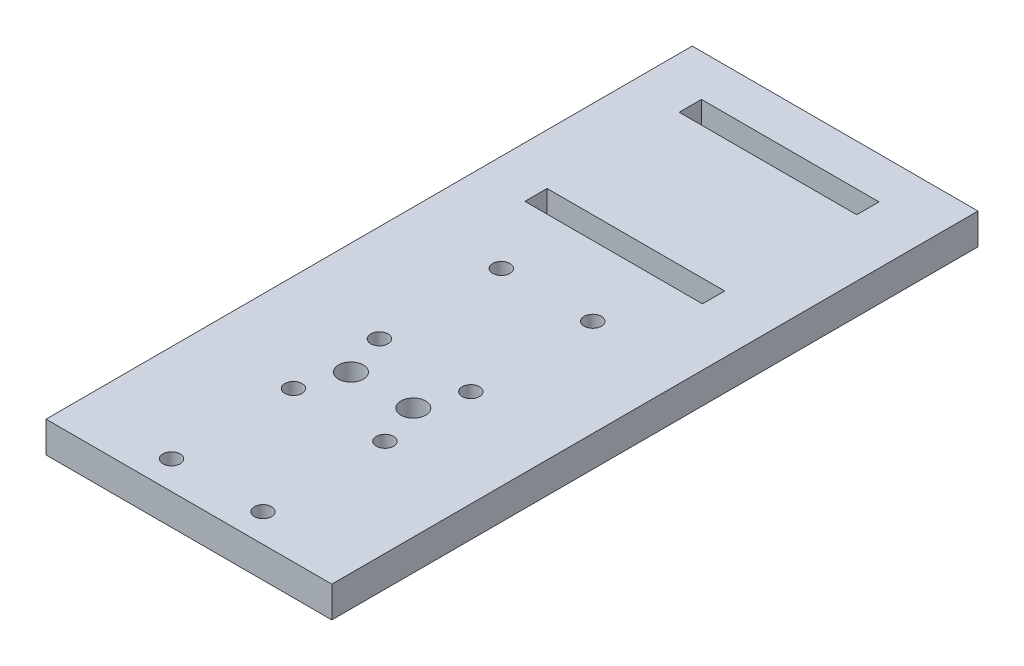
from build123d import *

# Parameters (mm, degrees)
SKETCH1_W           = 55
SKETCH1_H           = 74.38
SKETCH1_R           = 1.66
SKETCH1_R_2         = 2.38125
BOSS_EXTRUDE1_DEPTH = 5.969
SKETCH2_W           = 55
SKETCH2_H           = 49.98
SKETCH2_W_2         = 34.17
SKETCH2_H_2         = 4.28
BOSS_EXTRUDE2_DEPTH = 5.969


with BuildPart() as part:
    # Sketch1 → Boss-Extrude1 (new body)
    with BuildSketch(Plane(origin=(0, 0, 0), x_dir=(1, 0, 0), z_dir=(0, 1, 0))):
        with Locations((27.5, 37.19)):
            Rectangle(SKETCH1_W, SKETCH1_H)
        with Locations((18.7, 68.92)):
            Circle(SKETCH1_R, mode=Mode.SUBTRACT)
        with Locations((36.3, 68.92)):
            Circle(SKETCH1_R, mode=Mode.SUBTRACT)
        with Locations((36.3, 45.46)):
            Circle(SKETCH1_R, mode=Mode.SUBTRACT)
        with Locations((18.7, 45.46)):
            Circle(SKETCH1_R, mode=Mode.SUBTRACT)
        with Locations((18.7, 28.92)):
            Circle(SKETCH1_R, mode=Mode.SUBTRACT)
        with Locations((36.3, 28.92)):
            Circle(SKETCH1_R, mode=Mode.SUBTRACT)
        with Locations((36.3, 5.46)):
            Circle(SKETCH1_R, mode=Mode.SUBTRACT)
        with Locations((18.7, 5.46)):
            Circle(SKETCH1_R, mode=Mode.SUBTRACT)
        with Locations((21.5, 37.19)):
            Circle(SKETCH1_R_2, mode=Mode.SUBTRACT)
        with Locations((33.5, 37.19)):
            Circle(SKETCH1_R_2, mode=Mode.SUBTRACT)
    extrude(amount=BOSS_EXTRUDE1_DEPTH)

    # Sketch2 → Boss-Extrude2 (add)
    with BuildSketch(Plane(origin=(0, 5.969, 0), x_dir=(1, 0, 0), z_dir=(0, 1, 0))):
        with Locations((27.5, 99.37)):
            Rectangle(SKETCH2_W, SKETCH2_H)
        with Locations((26.865, 84.52)):
            Rectangle(SKETCH2_W_2, SKETCH2_H_2, mode=Mode.SUBTRACT)
        with Locations((26.865, 114.22)):
            Rectangle(SKETCH2_W_2, SKETCH2_H_2, mode=Mode.SUBTRACT)
    extrude(amount=-BOSS_EXTRUDE2_DEPTH)


solid = part.part
